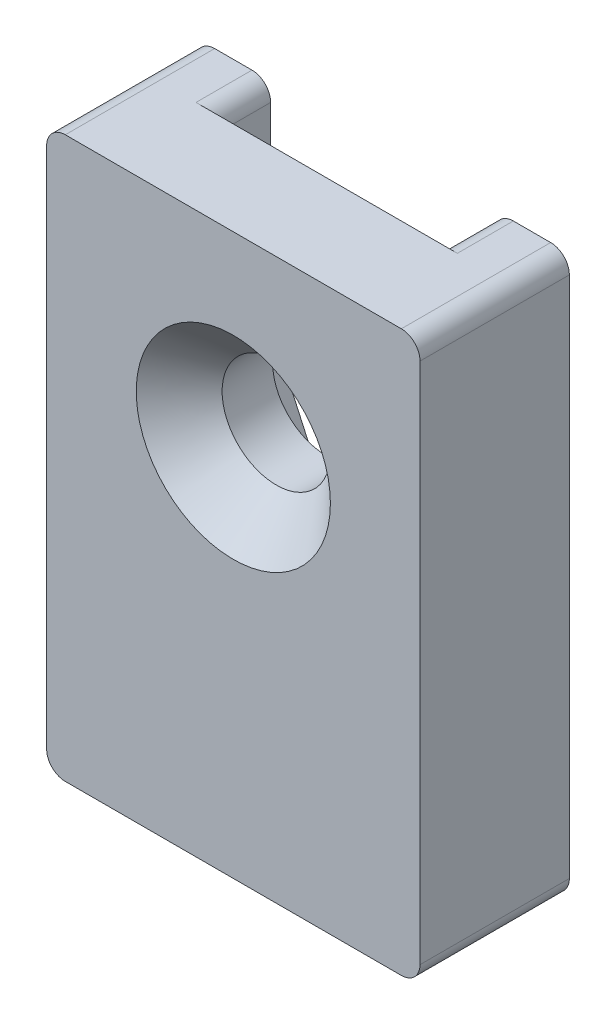
from build123d import *

# Parameters (mm, degrees)
SKETCH3_W                                       = 20
SKETCH3_H                                       = 30
BOSS_EXTRUDE1_DEPTH                             = 4
SKETCH4_W                                       = 12
SKETCH4_H                                       = 30
CUT_EXTRUDE1_DEPTH                              = 3
CSK_FOR_M5_FLAT_HEAD_MACHINE_SCREW1_D           = 5.8
CSK_FOR_M5_FLAT_HEAD_MACHINE_SCREW1_CSINK_D     = 10.4
CSK_FOR_M5_FLAT_HEAD_MACHINE_SCREW1_CSINK_ANGLE = 90
BOSS_EXTRUDE2_DEPTH                             = 3
FILLET1_R                                       = 1


with BuildPart() as part:
    # Sketch3 → Boss-Extrude1 (new body, symmetric)
    with BuildSketch(Plane.XY):
        Rectangle(SKETCH3_W, SKETCH3_H)
    extrude(amount=BOSS_EXTRUDE1_DEPTH, both=True)

    # Sketch4 → Cut-Extrude1 (cut)
    with BuildSketch(Plane(origin=(0, 0, -4), x_dir=(-1, 0, 0), z_dir=(0, 0, -1))):
        Rectangle(SKETCH4_W, SKETCH4_H)
    extrude(amount=-CUT_EXTRUDE1_DEPTH, mode=Mode.SUBTRACT)

    # CSK for M5 Flat Head Machine Screw1 (through all)
    with Locations(Plane(origin=(0, 5, 4), x_dir=(1, 0, 0), z_dir=(0, 0, 1))):
        with Locations((0, 0)):
            CounterSinkHole(CSK_FOR_M5_FLAT_HEAD_MACHINE_SCREW1_D / 2, CSK_FOR_M5_FLAT_HEAD_MACHINE_SCREW1_CSINK_D / 2, counter_sink_angle=CSK_FOR_M5_FLAT_HEAD_MACHINE_SCREW1_CSINK_ANGLE)

    # Sketch7 → Boss-Extrude2 (add)
    with BuildSketch(Plane(origin=(0, 0, -1), x_dir=(-1, 0, 0), z_dir=(0, 0, -1))):
        with BuildLine():
            Line((5.462217277, 2.51722284), (-2.5, -15))
            Line((-2.5, -15), (6, -15))
            Line((6, -15), (6, 5))
            ThreePointArc((6, 5), (5.864013287, 3.729823567), (5.462217277, 2.51722284))
        make_face()
    extrude(amount=BOSS_EXTRUDE2_DEPTH)

    # Fillet1
    fillet1_edges = [part.edges().sort_by_distance(p)[0] for p in [
        (6, -15, -2.5),
        (6, 15, -2.5),
        (-6, 15, -2.5),
        (2.5, -15, -2.5),
        (-10, 15, 0),
        (10, 15, 0),
        (10, -15, 0),
        (-10, -15, 0),
    ]]
    fillet(fillet1_edges, radius=FILLET1_R)


solid = part.part
